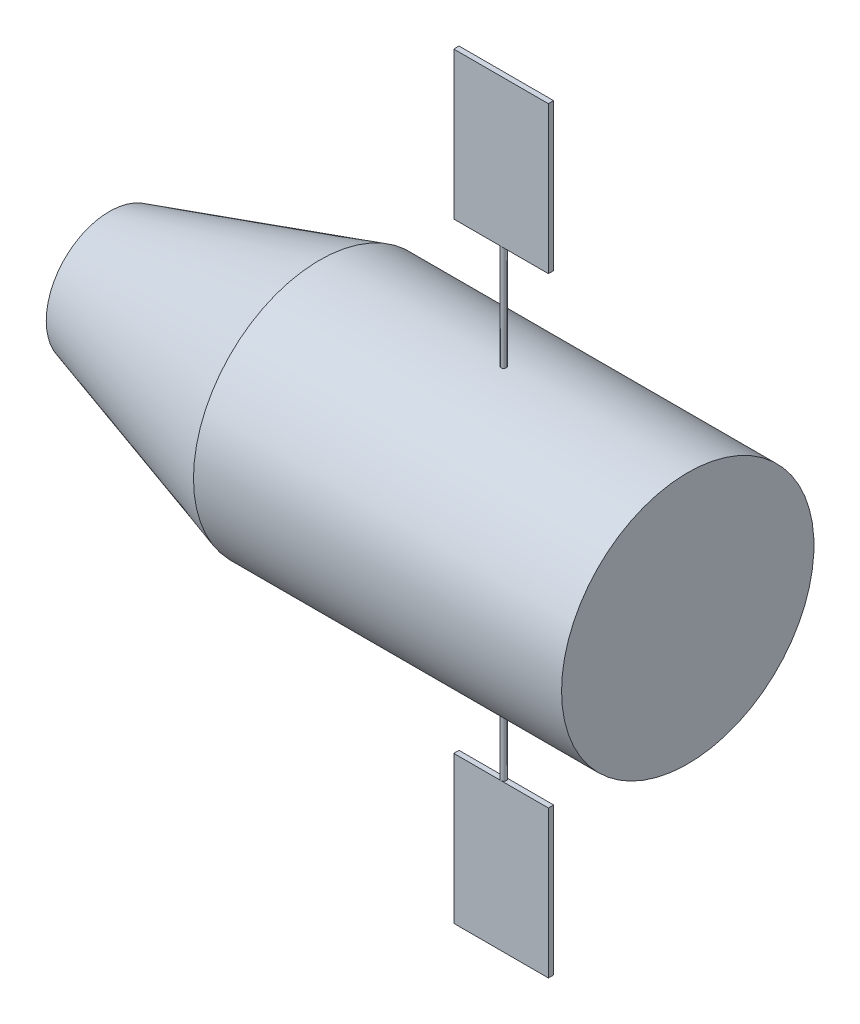
from build123d import *

# Parameters (mm, degrees)
SKETCH2_R        = 0.5
EXTRUDE1_DEPTH   = 44
SKETCH3_W        = 18
SKETCH3_H        = 28
EXTRUDE2_DEPTH   = 0.5
EXTRUDE2_2_DEPTH = 0.5


with BuildPart() as part:
    # Sketch1 → Revolve1 (revolve)
    with BuildSketch(Plane.XY, mode=Mode.PRIVATE) as revolve1_sk:
        Polygon((0, 0), (110, 0), (110, 24), (40, 24), (0, 12), align=None)
    revolve(revolve1_sk.sketch.rotate(Axis((0, 0, 0), (1, 0, 0)), 90), axis=Axis((0, 0, 0), (1, 0, 0)))  # turned: the seam where the file's is

    # Sketch2 → Extrude1 (add, symmetric)
    with BuildSketch(Plane(origin=(0, 0, 0), x_dir=(1, 0, 0), z_dir=(0, 1, 0))):
        with Locations(Location((75, 0, 0), (0, 0, 90))):  # turned: the seam where the file's is
            Circle(SKETCH2_R)
    extrude(amount=EXTRUDE1_DEPTH, both=True)


with BuildPart() as body_2:
    # Sketch3 → Extrude2 (new body, symmetric)
    with BuildSketch(Plane.XY):
        with Locations((75, 58)):
            Rectangle(SKETCH3_W, SKETCH3_H)
    extrude(amount=EXTRUDE2_DEPTH, both=True)


with BuildPart() as body_3:
    # Sketch3 → Extrude2 2 (new body, symmetric)
    with BuildSketch(Plane.XY):
        with Locations((75, -58)):
            Rectangle(SKETCH3_W, SKETCH3_H)
    extrude(amount=EXTRUDE2_2_DEPTH, both=True)


solid = Compound([part.part, body_2.part, body_3.part])
